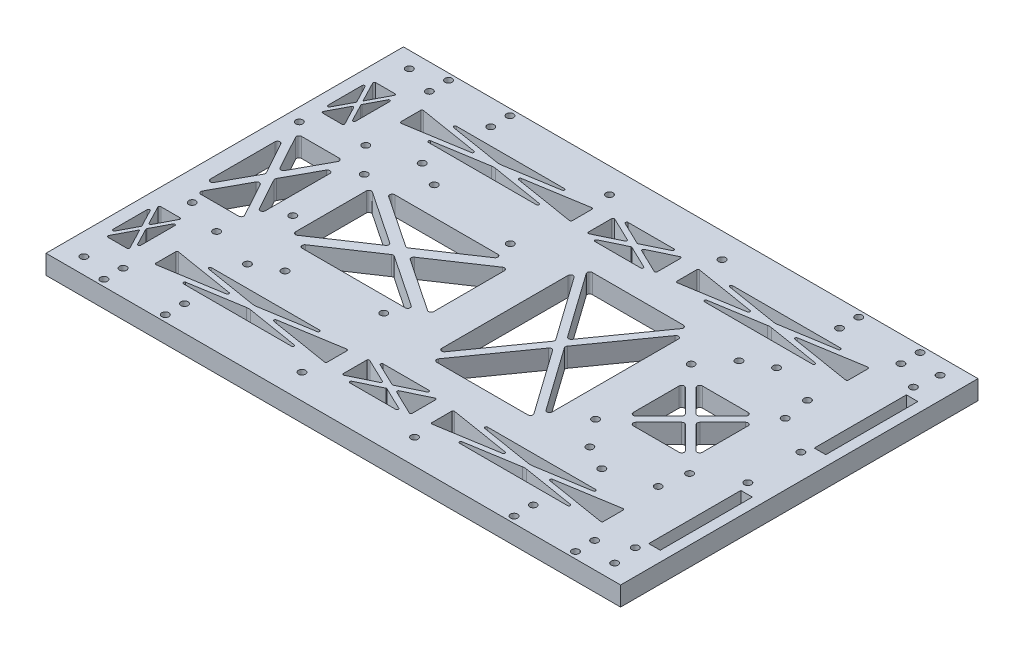
from build123d import *

# Parameters (mm, degrees)
SKETCH6_W                               = 224.59
SKETCH6_H                               = 139.7
CHASSISBASE_DEPTH                       = 7.5
ARDUINOMEGAMOUNTINGHOLESSKETCH_R        = 1.375
ARDUINOMEGAMOUNTINGHOLES_DEPTH          = 7.5
FRONTMOTORMOUNTINGHOLESSKETCH_R         = 1.375
FRONTMOTORMOUNTINGHOLES_DEPTH           = 7.5
L298MOTORDRIVERMOUNTINGHOLESSKETCH_R    = 1.375
L298MOTORDRIVERMOUNTINGHOLES_DEPTH      = 7.5
COUPLINGCOLLARMOUNTINGHOLESSKETCH_R     = 1.375
COUPLINGCOLLARMOUNTINGHOLES_DEPTH       = 7.5
SIDEDISTANCESENSORMOUNTINGHOLESSKETCH_R = 1.375
SIDEDISTANCESENSORMOUNTINGHOLES_DEPTH   = 7.5
TOPCHASSISMOUNTINGHOLESSKETCH_R         = 1.375
TOPCHASSISMOUNTINGHOLES_DEPTH           = 7.5
REARSENSORMOUNTINGHOLESSKETCH_R         = 1.375
REARSENSORMOUNTINGHOLES_DEPTH           = 7.5
SKETCH7_W                               = 4.5
SKETCH7_H                               = 36
WEIGHTREDUCTION_DEPTH                   = 8.5


with BuildPart() as part:
    # Sketch6 → chassisBase (new body)
    with BuildSketch(Plane(origin=(0, 0, 0), x_dir=(1, 0, 0), z_dir=(0, 1, 0))):
        with Locations((112.295, 26.65)):
            Rectangle(SKETCH6_W, SKETCH6_H)
    extrude(amount=CHASSISBASE_DEPTH)

    # arduinoMegaMountingHolesSketch → arduinoMegaMountingHoles (cut)
    with BuildSketch(Plane(origin=(0, 0, 0), x_dir=(1, 0, 0), z_dir=(0, 1, 0))):
        with Locations((5.05, 50.76)):
            Circle(ARDUINOMEGAMOUNTINGHOLESSKETCH_R)
        with Locations((87.52, 50.76)):
            Circle(ARDUINOMEGAMOUNTINGHOLESSKETCH_R)
        with Locations((86.29, 2.54)):
            Circle(ARDUINOMEGAMOUNTINGHOLESSKETCH_R)
        with Locations((11.41, 2.54)):
            Circle(ARDUINOMEGAMOUNTINGHOLESSKETCH_R)
        with Locations((35.5, 45.68)):
            Circle(ARDUINOMEGAMOUNTINGHOLESSKETCH_R)
        with Locations((35.5, 17.77)):
            Circle(ARDUINOMEGAMOUNTINGHOLESSKETCH_R)
    extrude(amount=ARDUINOMEGAMOUNTINGHOLES_DEPTH, mode=Mode.SUBTRACT)

    # frontMotorMountingHolesSketch → frontMotorMountingHoles (cut)
    with BuildSketch(Plane(origin=(0, 0, 0), x_dir=(1, 0, 0), z_dir=(0, 1, 0))):
        with Locations((25.985, 55.8)):
            Circle(FRONTMOTORMOUNTINGHOLESSKETCH_R)
        with Locations((43.035, 60.8)):
            Circle(FRONTMOTORMOUNTINGHOLESSKETCH_R)
        with Locations((52.735, 55.8)):
            Circle(FRONTMOTORMOUNTINGHOLESSKETCH_R)
        with Locations((25.985, -2.5)):
            Circle(FRONTMOTORMOUNTINGHOLESSKETCH_R)
        with Locations((43.035, -7.5)):
            Circle(FRONTMOTORMOUNTINGHOLESSKETCH_R)
        with Locations((52.735, -2.5)):
            Circle(FRONTMOTORMOUNTINGHOLESSKETCH_R)
    extrude(amount=FRONTMOTORMOUNTINGHOLES_DEPTH, mode=Mode.SUBTRACT)

    # L298motorDriverMountingHolesSketch → L298motorDriverMountingHoles (cut)
    with BuildSketch(Plane(origin=(0, 0, 0), x_dir=(1, 0, 0), z_dir=(0, 1, 0))):
        with Locations((163.60569727, 45.38594237)):
            Circle(L298MOTORDRIVERMOUNTINGHOLESSKETCH_R)
        with Locations((163.60569727, 8.0064415)):
            Circle(L298MOTORDRIVERMOUNTINGHOLESSKETCH_R)
        with Locations((200.347497622, 45.38594237)):
            Circle(L298MOTORDRIVERMOUNTINGHOLESSKETCH_R)
        with Locations((200.34749759, 8.0064415)):
            Circle(L298MOTORDRIVERMOUNTINGHOLESSKETCH_R)
        with Locations((171.855, 55.8)):
            Circle(L298MOTORDRIVERMOUNTINGHOLESSKETCH_R)
        with Locations((181.555, 60.8)):
            Circle(L298MOTORDRIVERMOUNTINGHOLESSKETCH_R)
        with Locations((198.605, 55.8)):
            Circle(L298MOTORDRIVERMOUNTINGHOLESSKETCH_R)
        with Locations((198.605, -2.5)):
            Circle(L298MOTORDRIVERMOUNTINGHOLESSKETCH_R)
        with Locations((181.555, -7.5)):
            Circle(L298MOTORDRIVERMOUNTINGHOLESSKETCH_R)
        with Locations((171.855, -2.5)):
            Circle(L298MOTORDRIVERMOUNTINGHOLESSKETCH_R)
    extrude(amount=L298MOTORDRIVERMOUNTINGHOLES_DEPTH, mode=Mode.SUBTRACT)

    # couplingCollarMountingHolesSketch → couplingCollarMountingHoles (cut)
    with BuildSketch(Plane(origin=(0, 0, 0), x_dir=(1, 0, 0), z_dir=(0, 1, 0))):
        with Locations((20.135, 86.5)):
            Circle(COUPLINGCOLLARMOUNTINGHOLESSKETCH_R)
        with Locations((20.135, 94)):
            Circle(COUPLINGCOLLARMOUNTINGHOLESSKETCH_R)
        with Locations((44.135, 86.5)):
            Circle(COUPLINGCOLLARMOUNTINGHOLESSKETCH_R)
        with Locations((44.135, 94)):
            Circle(COUPLINGCOLLARMOUNTINGHOLESSKETCH_R)
        with Locations((204.455, 86.5)):
            Circle(COUPLINGCOLLARMOUNTINGHOLESSKETCH_R)
        with Locations((180.455, 86.5)):
            Circle(COUPLINGCOLLARMOUNTINGHOLESSKETCH_R)
        with Locations((180.455, 94)):
            Circle(COUPLINGCOLLARMOUNTINGHOLESSKETCH_R)
        with Locations((204.455, 94)):
            Circle(COUPLINGCOLLARMOUNTINGHOLESSKETCH_R)
        with Locations((20.135, -33.2)):
            Circle(COUPLINGCOLLARMOUNTINGHOLESSKETCH_R)
        with Locations((44.135, -33.2)):
            Circle(COUPLINGCOLLARMOUNTINGHOLESSKETCH_R)
        with Locations((44.135, -40.7)):
            Circle(COUPLINGCOLLARMOUNTINGHOLESSKETCH_R)
        with Locations((20.135, -40.7)):
            Circle(COUPLINGCOLLARMOUNTINGHOLESSKETCH_R)
        with Locations((180.455, -33.2)):
            Circle(COUPLINGCOLLARMOUNTINGHOLESSKETCH_R)
        with Locations((204.455, -33.2)):
            Circle(COUPLINGCOLLARMOUNTINGHOLESSKETCH_R)
        with Locations((204.455, -40.7)):
            Circle(COUPLINGCOLLARMOUNTINGHOLESSKETCH_R)
        with Locations((180.455, -40.7)):
            Circle(COUPLINGCOLLARMOUNTINGHOLESSKETCH_R)
    extrude(amount=COUPLINGCOLLARMOUNTINGHOLES_DEPTH, mode=Mode.SUBTRACT)

    # sideDistanceSensorMountingHolesSketch → sideDistanceSensorMountingHoles (cut)
    with BuildSketch(Plane(origin=(0, 0, 0), x_dir=(1, 0, 0), z_dir=(0, 1, 0))):
        with Locations((90.295, -33.45)):
            Circle(SIDEDISTANCESENSORMOUNTINGHOLESSKETCH_R)
        with Locations((134.295, -33.45)):
            Circle(SIDEDISTANCESENSORMOUNTINGHOLESSKETCH_R)
        with Locations((90.295, 86.75)):
            Circle(SIDEDISTANCESENSORMOUNTINGHOLESSKETCH_R)
        with Locations((134.295, 86.75)):
            Circle(SIDEDISTANCESENSORMOUNTINGHOLESSKETCH_R)
    extrude(amount=SIDEDISTANCESENSORMOUNTINGHOLES_DEPTH, mode=Mode.SUBTRACT)

    # topChassisMountingHolesSketch → topChassisMountingHoles (cut)
    with BuildSketch(Plane(origin=(0, 0, 0), x_dir=(1, 0, 0), z_dir=(0, 1, 0))):
        with Locations((8.5675, 90.25)):
            Circle(TOPCHASSISMOUNTINGHOLESSKETCH_R)
        with Locations((8.5675, -36.95)):
            Circle(TOPCHASSISMOUNTINGHOLESSKETCH_R)
        with Locations((216.0225, 90.25)):
            Circle(TOPCHASSISMOUNTINGHOLESSKETCH_R)
        with Locations((216.0225, -36.95)):
            Circle(TOPCHASSISMOUNTINGHOLESSKETCH_R)
    extrude(amount=TOPCHASSISMOUNTINGHOLES_DEPTH, mode=Mode.SUBTRACT)

    # rearSensorMountingHolesSketch → rearSensorMountingHoles (cut)
    with BuildSketch(Plane(origin=(0, 0, 0), x_dir=(1, 0, 0), z_dir=(0, 1, 0))):
        with Locations((214.84, 81)):
            Circle(REARSENSORMOUNTINGHOLESSKETCH_R)
        with Locations((214.84, 37)):
            Circle(REARSENSORMOUNTINGHOLESSKETCH_R)
        with Locations((214.84, -27.7)):
            Circle(REARSENSORMOUNTINGHOLESSKETCH_R)
        with Locations((214.84, 16.3)):
            Circle(REARSENSORMOUNTINGHOLESSKETCH_R)
    extrude(amount=REARSENSORMOUNTINGHOLES_DEPTH, mode=Mode.SUBTRACT)

    # Sketch7 → weightReduction (cut, through all)
    with BuildSketch(Plane(origin=(0, 7.5, 0), x_dir=(1, 0, 0), z_dir=(0, 1, 0))):
        with BuildLine():
            Line((170.362106781, 36.321572875), (179.326572875, 27.357106781))
            ThreePointArc((179.326572875, 27.357106781), (179.619466094, 26.65), (179.326572875, 25.942893219))
            Line((179.326572875, 25.942893219), (170.362106781, 16.978427125))
            ThreePointArc((170.362106781, 16.978427125), (169.272316568, 16.761654373), (168.655, 17.685533906))
            Line((168.655, 17.685533906), (168.655, 35.614466094))
            ThreePointArc((168.655, 35.614466094), (169.272316568, 36.538345627), (170.362106781, 36.321572875))
        make_face()
        with BuildLine():
            Line((172.483427125, 38.442893219), (181.447893219, 29.478427125))
            ThreePointArc((181.447893219, 29.478427125), (182.155, 29.185533906), (182.862106781, 29.478427125))
            Line((182.862106781, 29.478427125), (191.826572875, 38.442893219))
            ThreePointArc((191.826572875, 38.442893219), (192.043345627, 39.532683432), (191.119466094, 40.15))
            Line((191.119466094, 40.15), (173.190533906, 40.15))
            ThreePointArc((173.190533906, 40.15), (172.266654373, 39.532683432), (172.483427125, 38.442893219))
        make_face()
        with BuildLine():
            Line((173.190533906, 13.15), (191.119466094, 13.15))
            ThreePointArc((191.119466094, 13.15), (192.043345627, 13.767316568), (191.826572875, 14.857106781))
            Line((191.826572875, 14.857106781), (182.862106781, 23.821572875))
            ThreePointArc((182.862106781, 23.821572875), (182.155, 24.114466094), (181.447893219, 23.821572875))
            Line((181.447893219, 23.821572875), (172.483427125, 14.857106781))
            ThreePointArc((172.483427125, 14.857106781), (172.266654373, 13.767316568), (173.190533906, 13.15))
        make_face()
        with BuildLine():
            Line((195.655, 17.685533906), (195.655, 35.614466094))
            ThreePointArc((195.655, 35.614466094), (195.037683432, 36.538345627), (193.947893219, 36.321572875))
            Line((193.947893219, 36.321572875), (184.983427125, 27.357106781))
            ThreePointArc((184.983427125, 27.357106781), (184.690533906, 26.65), (184.983427125, 25.942893219))
            Line((184.983427125, 25.942893219), (193.947893219, 16.978427125))
            ThreePointArc((193.947893219, 16.978427125), (195.037683432, 16.761654373), (195.655, 17.685533906))
        make_face()
        with BuildLine():
            Line((113.294715761, -3.75), (148.880284239, -3.75))
            ThreePointArc((148.880284239, -3.75), (149.768717571, -3.209005681), (149.695876132, -2.17137243))
            Line((149.695876132, -2.17137243), (131.903091892, 22.908059163))
            ThreePointArc((131.903091892, 22.908059163), (131.0875, 23.329431593), (130.271908108, 22.908059163))
            Line((130.271908108, 22.908059163), (112.479123868, -2.17137243))
            ThreePointArc((112.479123868, -2.17137243), (112.406282429, -3.209005681), (113.294715761, -3.75))
        make_face()
        with BuildLine():
            Line((109.52, 1.980096633), (109.52, 51.319903367))
            ThreePointArc((109.52, 51.319903367), (110.216348796, 52.27268663), (111.335591892, 51.898530938))
            Line((111.335591892, 51.898530938), (128.837833368, 27.22862757))
            ThreePointArc((128.837833368, 27.22862757), (129.022241476, 26.65), (128.837833368, 26.07137243))
            Line((128.837833368, 26.07137243), (111.335591892, 1.401469062))
            ThreePointArc((111.335591892, 1.401469062), (110.216348796, 1.02731337), (109.52, 1.980096633))
        make_face()
        with BuildLine():
            Line((113.294715761, 57.05), (148.880284239, 57.05))
            ThreePointArc((148.880284239, 57.05), (149.768717571, 56.509005681), (149.695876132, 55.47137243))
            Line((149.695876132, 55.47137243), (131.903091892, 30.391940837))
            ThreePointArc((131.903091892, 30.391940837), (131.0875, 29.970568407), (130.271908108, 30.391940837))
            Line((130.271908108, 30.391940837), (112.479123868, 55.47137243))
            ThreePointArc((112.479123868, 55.47137243), (112.406282429, 56.509005681), (113.294715761, 57.05))
        make_face()
        with BuildLine():
            Line((152.655, 1.980096633), (152.655, 51.319903367))
            ThreePointArc((152.655, 51.319903367), (151.958651204, 52.27268663), (150.839408108, 51.898530938))
            Line((150.839408108, 51.898530938), (133.337166632, 27.22862757))
            ThreePointArc((133.337166632, 27.22862757), (133.152758524, 26.65), (133.337166632, 26.07137243))
            Line((133.337166632, 26.07137243), (150.839408108, 1.401469062))
            ThreePointArc((150.839408108, 1.401469062), (151.958651204, 1.02731337), (152.655, 1.980096633))
        make_face()
        with BuildLine():
            Line((103.334561275, 81), (121.255438725, 81))
            ThreePointArc((121.255438725, 81), (121.742926141, 80.611157634), (121.472190515, 80.049424078))
            Line((121.472190515, 80.049424078), (112.51175179, 75.738960427))
            ThreePointArc((112.51175179, 75.738960427), (112.295, 75.689536349), (112.07824821, 75.738960427))
            Line((112.07824821, 75.738960427), (103.117809485, 80.049424078))
            ThreePointArc((103.117809485, 80.049424078), (102.847073859, 80.611157634), (103.334561275, 81))
        make_face()
        with BuildLine():
            Line((125.755, 69.955063838), (125.755, 79.094936162))
            ThreePointArc((125.755, 79.094936162), (125.521105341, 79.518242136), (125.03824821, 79.545512084))
            Line((125.03824821, 79.545512084), (115.538427245, 74.975575922))
            ThreePointArc((115.538427245, 74.975575922), (115.255179035, 74.525), (115.538427245, 74.074424078))
            Line((115.538427245, 74.074424078), (125.03824821, 69.504487916))
            ThreePointArc((125.03824821, 69.504487916), (125.521105341, 69.531757864), (125.755, 69.955063838))
        make_face()
        with BuildLine():
            Line((37.11356333, -25.706546713), (57.528535299, -22.370069951))
            ThreePointArc((57.528535299, -22.370069951), (58.335, -22.304602825), (59.141464701, -22.370069951))
            Line((59.141464701, -22.370069951), (79.55643667, -25.706546713))
            ThreePointArc((79.55643667, -25.706546713), (79.974150834, -26.240455879), (79.4757902, -26.7))
            Line((79.4757902, -26.7), (37.1942098, -26.7))
            ThreePointArc((37.1942098, -26.7), (36.695849166, -26.240455879), (37.11356333, -25.706546713))
        make_face()
        with BuildLine():
            Line((6.672598406, 58.3), (14.162401594, 58.3))
            ThreePointArc((14.162401594, 58.3), (14.59014905, 58.541094392), (14.605386455, 59.031871544))
            Line((14.605386455, 59.031871544), (10.860484861, 66.186413584))
            ThreePointArc((10.860484861, 66.186413584), (10.4175, 66.454542039), (9.974515139, 66.186413584))
            Line((9.974515139, 66.186413584), (6.229613545, 59.031871544))
            ThreePointArc((6.229613545, 59.031871544), (6.24485095, 58.541094392), (6.672598406, 58.3))
        make_face()
        with BuildLine():
            Line((5, 61.950695617), (5, 75.349304383))
            ThreePointArc((5, 75.349304383), (5.380610784, 75.834841421), (5.942984861, 75.581175928))
            Line((5.942984861, 75.581175928), (9.449601431, 68.881871544))
            ThreePointArc((9.449601431, 68.881871544), (9.50661657, 68.65), (9.449601431, 68.418128456))
            Line((9.449601431, 68.418128456), (5.942984861, 61.718824072))
            ThreePointArc((5.942984861, 61.718824072), (5.380610784, 61.465158579), (5, 61.950695617))
        make_face()
        with BuildLine():
            Line((6.672598406, 79), (14.162401594, 79))
            ThreePointArc((14.162401594, 79), (14.59014905, 78.758905608), (14.605386455, 78.268128456))
            Line((14.605386455, 78.268128456), (10.4175, 70.267274776))
            Line((10.4175, 70.267274776), (6.229613545, 78.268128456))
            ThreePointArc((6.229613545, 78.268128456), (6.24485095, 78.758905608), (6.672598406, 79))
        make_face()
        with BuildLine():
            Line((15.835, 61.950695617), (15.835, 75.349304383))
            ThreePointArc((15.835, 75.349304383), (15.454389216, 75.834841421), (14.892015139, 75.581175928))
            Line((14.892015139, 75.581175928), (11.385398569, 68.881871544))
            ThreePointArc((11.385398569, 68.881871544), (11.32838343, 68.65), (11.385398569, 68.418128456))
            Line((11.385398569, 68.418128456), (14.892015139, 61.718824072))
            ThreePointArc((14.892015139, 61.718824072), (15.454389216, 61.465158579), (15.835, 61.950695617))
        make_face()
        with BuildLine():
            Line((24.835, -17.351617124), (24.835, -25.098382876))
            ThreePointArc((24.835, -25.098382876), (25.011212442, -25.479383686), (25.41564647, -25.591836163))
            Line((25.41564647, -25.591836163), (49.1157974, -21.718453287))
            ThreePointArc((49.1157974, -21.718453287), (49.53515093, -21.225), (49.1157974, -20.731546713))
            Line((49.1157974, -20.731546713), (25.41564647, -16.858163837))
            ThreePointArc((25.41564647, -16.858163837), (25.011212442, -16.970616314), (24.835, -17.351617124))
        make_face()
        with BuildLine():
            Line((91.835, -25.098382876), (91.835, -17.351617124))
            ThreePointArc((91.835, -17.351617124), (91.658787558, -16.970616314), (91.25435353, -16.858163837))
            Line((91.25435353, -16.858163837), (67.5542026, -20.731546713))
            ThreePointArc((67.5542026, -20.731546713), (67.13484907, -21.225), (67.5542026, -21.718453287))
            Line((67.5542026, -21.718453287), (91.25435353, -25.591836163))
            ThreePointArc((91.25435353, -25.591836163), (91.658787558, -25.479383686), (91.835, -25.098382876))
        make_face()
        with BuildLine():
            Line((79.4757902, -15.75), (37.1942098, -15.75))
            ThreePointArc((37.1942098, -15.75), (36.695849166, -16.209544121), (37.11356333, -16.743453287))
            Line((37.11356333, -16.743453287), (57.528535299, -20.079930049))
            ThreePointArc((57.528535299, -20.079930049), (58.335, -20.145397175), (59.141464701, -20.079930049))
            Line((59.141464701, -20.079930049), (79.55643667, -16.743453287))
            ThreePointArc((79.55643667, -16.743453287), (79.974150834, -16.209544121), (79.4757902, -15.75))
        make_face()
        with BuildLine():
            Line((10.396733566, 46.3), (25.103266434, 46.3))
            ThreePointArc((25.103266434, 46.3), (25.963483437, 45.809928139), (25.980564146, 44.820053415))
            Line((25.980564146, 44.820053415), (18.627297712, 31.378966398))
            ThreePointArc((18.627297712, 31.378966398), (17.75, 30.858912984), (16.872702288, 31.378966398))
            Line((16.872702288, 31.378966398), (9.519435854, 44.820053415))
            ThreePointArc((9.519435854, 44.820053415), (9.536516563, 45.809928139), (10.396733566, 46.3))
        make_face()
        with BuildLine():
            Line((28.5, 14.036819961), (28.5, 39.263180039))
            ThreePointArc((28.5, 39.263180039), (27.747691631, 40.232018961), (26.622702288, 39.743126625))
            Line((26.622702288, 39.743126625), (19.722362063, 27.129946585))
            ThreePointArc((19.722362063, 27.129946585), (19.599659775, 26.65), (19.722362063, 26.170053415))
            Line((19.722362063, 26.170053415), (26.622702288, 13.556873375))
            ThreePointArc((26.622702288, 13.556873375), (27.747691631, 13.067981039), (28.5, 14.036819961))
        make_face()
        with BuildLine():
            Line((10.396733566, 7), (25.103266434, 7))
            ThreePointArc((25.103266434, 7), (25.963483437, 7.490071861), (25.980564146, 8.479946585))
            Line((25.980564146, 8.479946585), (18.627297712, 21.921033602))
            ThreePointArc((18.627297712, 21.921033602), (17.75, 22.441087016), (16.872702288, 21.921033602))
            Line((16.872702288, 21.921033602), (9.519435854, 8.479946585))
            ThreePointArc((9.519435854, 8.479946585), (9.536516563, 7.490071861), (10.396733566, 7))
        make_face()
        with BuildLine():
            Line((7, 14.036819961), (7, 39.263180039))
            ThreePointArc((7, 39.263180039), (7.752308369, 40.232018961), (8.877297712, 39.743126625))
            Line((8.877297712, 39.743126625), (15.777637937, 27.129946585))
            ThreePointArc((15.777637937, 27.129946585), (15.900340225, 26.65), (15.777637937, 26.170053415))
            Line((15.777637937, 26.170053415), (8.877297712, 13.556873375))
            ThreePointArc((8.877297712, 13.556873375), (7.752308369, 13.067981039), (7, 14.036819961))
        make_face()
        with BuildLine():
            Line((48.37842286, 44.76), (88.64157714, 44.76))
            ThreePointArc((88.64157714, 44.76), (89.598285248, 44.051049131), (89.198475267, 42.929419193))
            Line((89.198475267, 42.929419193), (69.066898127, 29.431349515))
            ThreePointArc((69.066898127, 29.431349515), (68.51, 29.261930322), (67.953101873, 29.431349515))
            Line((67.953101873, 29.431349515), (47.821524733, 42.929419193))
            ThreePointArc((47.821524733, 42.929419193), (47.421714752, 44.051049131), (48.37842286, 44.76))
        make_face()
        with BuildLine():
            Line((95.52, 12.822422732), (95.52, 40.477577268))
            ThreePointArc((95.52, 40.477577268), (94.990691976, 41.359874873), (93.963101873, 41.308158075))
            Line((93.963101873, 41.308158075), (73.34008354, 27.480580807))
            ThreePointArc((73.34008354, 27.480580807), (72.896981667, 26.65), (73.34008354, 25.819419193))
            Line((73.34008354, 25.819419193), (93.963101873, 11.991841925))
            ThreePointArc((93.963101873, 11.991841925), (94.990691976, 11.940125127), (95.52, 12.822422732))
        make_face()
        with BuildLine():
            Line((48.37842286, 8.54), (88.64157714, 8.54))
            ThreePointArc((88.64157714, 8.54), (89.598285248, 9.248950869), (89.198475267, 10.370580807))
            Line((89.198475267, 10.370580807), (69.066898127, 23.868650485))
            ThreePointArc((69.066898127, 23.868650485), (68.51, 24.038069678), (67.953101873, 23.868650485))
            Line((67.953101873, 23.868650485), (47.821524733, 10.370580807))
            ThreePointArc((47.821524733, 10.370580807), (47.421714752, 9.248950869), (48.37842286, 8.54))
        make_face()
        with BuildLine():
            Line((41.5, 12.822422732), (41.5, 40.477577268))
            ThreePointArc((41.5, 40.477577268), (42.029308024, 41.359874873), (43.056898127, 41.308158075))
            Line((43.056898127, 41.308158075), (63.67991646, 27.480580807))
            ThreePointArc((63.67991646, 27.480580807), (64.123018333, 26.65), (63.67991646, 25.819419193))
            Line((63.67991646, 25.819419193), (43.056898127, 11.991841925))
            ThreePointArc((43.056898127, 11.991841925), (42.029308024, 11.940125127), (41.5, 12.822422732))
        make_face()
        with BuildLine():
            Line((103.334561275, 68.05), (121.255438725, 68.05))
            ThreePointArc((121.255438725, 68.05), (121.742926141, 68.438842366), (121.472190515, 69.000575922))
            Line((121.472190515, 69.000575922), (112.51175179, 73.311039573))
            ThreePointArc((112.51175179, 73.311039573), (112.295, 73.360463651), (112.07824821, 73.311039573))
            Line((112.07824821, 73.311039573), (103.117809485, 69.000575922))
            ThreePointArc((103.117809485, 69.000575922), (102.847073859, 68.438842366), (103.334561275, 68.05))
        make_face()
        with BuildLine():
            Line((98.835, 69.955063838), (98.835, 79.094936162))
            ThreePointArc((98.835, 79.094936162), (99.068894659, 79.518242136), (99.55175179, 79.545512084))
            Line((99.55175179, 79.545512084), (109.051572755, 74.975575922))
            ThreePointArc((109.051572755, 74.975575922), (109.334820965, 74.525), (109.051572755, 74.074424078))
            Line((109.051572755, 74.074424078), (99.55175179, 69.504487916))
            ThreePointArc((99.55175179, 69.504487916), (99.068894659, 69.531757864), (98.835, 69.955063838))
        make_face()
        with BuildLine():
            Line((25.41564647, 70.158163837), (49.1157974, 74.031546713))
            ThreePointArc((49.1157974, 74.031546713), (49.53515093, 74.525), (49.1157974, 75.018453287))
            Line((49.1157974, 75.018453287), (25.41564647, 78.891836163))
            ThreePointArc((25.41564647, 78.891836163), (25.011212442, 78.779383686), (24.835, 78.398382876))
            Line((24.835, 78.398382876), (24.835, 70.651617124))
            ThreePointArc((24.835, 70.651617124), (25.011212442, 70.270616314), (25.41564647, 70.158163837))
        make_face()
        with BuildLine():
            Line((37.11356333, 79.006546713), (57.528535299, 75.670069951))
            ThreePointArc((57.528535299, 75.670069951), (58.335, 75.604602825), (59.141464701, 75.670069951))
            Line((59.141464701, 75.670069951), (79.55643667, 79.006546713))
            ThreePointArc((79.55643667, 79.006546713), (79.974150834, 79.540455879), (79.4757902, 80))
            Line((79.4757902, 80), (37.1942098, 80))
            ThreePointArc((37.1942098, 80), (36.695849166, 79.540455879), (37.11356333, 79.006546713))
        make_face()
        with BuildLine():
            Line((67.5542026, 75.018453287), (91.25435353, 78.891836163))
            ThreePointArc((91.25435353, 78.891836163), (91.658787558, 78.779383686), (91.835, 78.398382876))
            Line((91.835, 78.398382876), (91.835, 70.651617124))
            ThreePointArc((91.835, 70.651617124), (91.658787558, 70.270616314), (91.25435353, 70.158163837))
            Line((91.25435353, 70.158163837), (67.5542026, 74.031546713))
            ThreePointArc((67.5542026, 74.031546713), (67.13484907, 74.525), (67.5542026, 75.018453287))
        make_face()
        with BuildLine():
            Line((59.141464701, 73.379930049), (79.55643667, 70.043453287))
            ThreePointArc((79.55643667, 70.043453287), (79.974150834, 69.509544121), (79.4757902, 69.05))
            Line((79.4757902, 69.05), (37.1942098, 69.05))
            ThreePointArc((37.1942098, 69.05), (36.695849166, 69.509544121), (37.11356333, 70.043453287))
            Line((37.11356333, 70.043453287), (57.528535299, 73.379930049))
            ThreePointArc((57.528535299, 73.379930049), (58.335, 73.445397175), (59.141464701, 73.379930049))
        make_face()
        with BuildLine():
            Line((157.0357974, -21.718453287), (133.33564647, -25.591836163))
            ThreePointArc((133.33564647, -25.591836163), (132.931212442, -25.479383686), (132.755, -25.098382876))
            Line((132.755, -25.098382876), (132.755, -17.351617124))
            ThreePointArc((132.755, -17.351617124), (132.931212442, -16.970616314), (133.33564647, -16.858163837))
            Line((133.33564647, -16.858163837), (157.0357974, -20.731546713))
            ThreePointArc((157.0357974, -20.731546713), (157.45515093, -21.225), (157.0357974, -21.718453287))
        make_face()
        with BuildLine():
            Line((187.47643667, -25.706546713), (167.061464701, -22.370069951))
            ThreePointArc((167.061464701, -22.370069951), (166.255, -22.304602825), (165.448535299, -22.370069951))
            Line((165.448535299, -22.370069951), (145.03356333, -25.706546713))
            ThreePointArc((145.03356333, -25.706546713), (144.615849166, -26.240455879), (145.1142098, -26.7))
            Line((145.1142098, -26.7), (187.3957902, -26.7))
            ThreePointArc((187.3957902, -26.7), (187.894150834, -26.240455879), (187.47643667, -25.706546713))
        make_face()
        with BuildLine():
            Line((199.17435353, -16.858163837), (175.4742026, -20.731546713))
            ThreePointArc((175.4742026, -20.731546713), (175.05484907, -21.225), (175.4742026, -21.718453287))
            Line((175.4742026, -21.718453287), (199.17435353, -25.591836163))
            ThreePointArc((199.17435353, -25.591836163), (199.578787558, -25.479383686), (199.755, -25.098382876))
            Line((199.755, -25.098382876), (199.755, -17.351617124))
            ThreePointArc((199.755, -17.351617124), (199.578787558, -16.970616314), (199.17435353, -16.858163837))
        make_face()
        with BuildLine():
            Line((165.448535299, -20.079930049), (145.03356333, -16.743453287))
            ThreePointArc((145.03356333, -16.743453287), (144.615849166, -16.209544121), (145.1142098, -15.75))
            Line((145.1142098, -15.75), (187.3957902, -15.75))
            ThreePointArc((187.3957902, -15.75), (187.894150834, -16.209544121), (187.47643667, -16.743453287))
            Line((187.47643667, -16.743453287), (167.061464701, -20.079930049))
            ThreePointArc((167.061464701, -20.079930049), (166.255, -20.145397175), (165.448535299, -20.079930049))
        make_face()
        with BuildLine():
            Line((187.47643667, 70.043453287), (167.061464701, 73.379930049))
            ThreePointArc((167.061464701, 73.379930049), (166.255, 73.445397175), (165.448535299, 73.379930049))
            Line((165.448535299, 73.379930049), (145.03356333, 70.043453287))
            ThreePointArc((145.03356333, 70.043453287), (144.615849166, 69.509544121), (145.1142098, 69.05))
            Line((145.1142098, 69.05), (187.3957902, 69.05))
            ThreePointArc((187.3957902, 69.05), (187.894150834, 69.509544121), (187.47643667, 70.043453287))
        make_face()
        with BuildLine():
            Line((157.0357974, 74.031546713), (133.33564647, 70.158163837))
            ThreePointArc((133.33564647, 70.158163837), (132.931212442, 70.270616314), (132.755, 70.651617124))
            Line((132.755, 70.651617124), (132.755, 78.398382876))
            ThreePointArc((132.755, 78.398382876), (132.931212442, 78.779383686), (133.33564647, 78.891836163))
            Line((133.33564647, 78.891836163), (157.0357974, 75.018453287))
            ThreePointArc((157.0357974, 75.018453287), (157.45515093, 74.525), (157.0357974, 74.031546713))
        make_face()
        with BuildLine():
            Line((187.3957902, 80), (145.1142098, 80))
            ThreePointArc((145.1142098, 80), (144.615849166, 79.540455879), (145.03356333, 79.006546713))
            Line((145.03356333, 79.006546713), (165.448535299, 75.670069951))
            ThreePointArc((165.448535299, 75.670069951), (166.255, 75.604602825), (167.061464701, 75.670069951))
            Line((167.061464701, 75.670069951), (187.47643667, 79.006546713))
            ThreePointArc((187.47643667, 79.006546713), (187.894150834, 79.540455879), (187.3957902, 80))
        make_face()
        with BuildLine():
            Line((199.755, 70.651617124), (199.755, 78.398382876))
            ThreePointArc((199.755, 78.398382876), (199.578787558, 78.779383686), (199.17435353, 78.891836163))
            Line((199.17435353, 78.891836163), (175.4742026, 75.018453287))
            ThreePointArc((175.4742026, 75.018453287), (175.05484907, 74.525), (175.4742026, 74.031546713))
            Line((175.4742026, 74.031546713), (199.17435353, 70.158163837))
            ThreePointArc((199.17435353, 70.158163837), (199.578787558, 70.270616314), (199.755, 70.651617124))
        make_face()
        with BuildLine():
            Line((5, -8.650695617), (5, -22.049304383))
            ThreePointArc((5, -22.049304383), (5.380610784, -22.534841421), (5.942984861, -22.281175928))
            Line((5.942984861, -22.281175928), (9.449601431, -15.581871544))
            ThreePointArc((9.449601431, -15.581871544), (9.50661657, -15.35), (9.449601431, -15.118128456))
            Line((9.449601431, -15.118128456), (5.942984861, -8.418824072))
            ThreePointArc((5.942984861, -8.418824072), (5.380610784, -8.165158579), (5, -8.650695617))
        make_face()
        with BuildLine():
            Line((6.229613545, -5.731871544), (9.974515139, -12.886413584))
            ThreePointArc((9.974515139, -12.886413584), (10.4175, -13.154542039), (10.860484861, -12.886413584))
            Line((10.860484861, -12.886413584), (14.605386455, -5.731871544))
            ThreePointArc((14.605386455, -5.731871544), (14.59014905, -5.241094392), (14.162401594, -5))
            Line((14.162401594, -5), (6.672598406, -5))
            ThreePointArc((6.672598406, -5), (6.24485095, -5.241094392), (6.229613545, -5.731871544))
        make_face()
        with BuildLine():
            Line((11.385398569, -15.581871544), (14.892015139, -22.281175928))
            ThreePointArc((14.892015139, -22.281175928), (15.454389216, -22.534841421), (15.835, -22.049304383))
            Line((15.835, -22.049304383), (15.835, -8.650695617))
            ThreePointArc((15.835, -8.650695617), (15.454389216, -8.165158579), (14.892015139, -8.418824072))
            Line((14.892015139, -8.418824072), (11.385398569, -15.118128456))
            ThreePointArc((11.385398569, -15.118128456), (11.32838343, -15.35), (11.385398569, -15.581871544))
        make_face()
        with BuildLine():
            Line((6.229613545, -24.968128456), (10.4175, -16.967274776))
            Line((10.4175, -16.967274776), (14.605386455, -24.968128456))
            ThreePointArc((14.605386455, -24.968128456), (14.59014905, -25.458905608), (14.162401594, -25.7))
            Line((14.162401594, -25.7), (6.672598406, -25.7))
            ThreePointArc((6.672598406, -25.7), (6.24485095, -25.458905608), (6.229613545, -24.968128456))
        make_face()
        with BuildLine():
            Line((115.538427245, -20.774424078), (125.03824821, -16.204487916))
            ThreePointArc((125.03824821, -16.204487916), (125.521105341, -16.231757864), (125.755, -16.655063838))
            Line((125.755, -16.655063838), (125.755, -25.794936162))
            ThreePointArc((125.755, -25.794936162), (125.521105341, -26.218242136), (125.03824821, -26.245512084))
            Line((125.03824821, -26.245512084), (115.538427245, -21.675575922))
            ThreePointArc((115.538427245, -21.675575922), (115.255179035, -21.225), (115.538427245, -20.774424078))
        make_face()
        with BuildLine():
            Line((103.117809485, -15.700575922), (112.07824821, -20.011039573))
            ThreePointArc((112.07824821, -20.011039573), (112.295, -20.060463651), (112.51175179, -20.011039573))
            Line((112.51175179, -20.011039573), (121.472190515, -15.700575922))
            ThreePointArc((121.472190515, -15.700575922), (121.742926141, -15.138842366), (121.255438725, -14.75))
            Line((121.255438725, -14.75), (103.334561275, -14.75))
            ThreePointArc((103.334561275, -14.75), (102.847073859, -15.138842366), (103.117809485, -15.700575922))
        make_face()
        with BuildLine():
            Line((99.55175179, -16.204487916), (109.051572755, -20.774424078))
            ThreePointArc((109.051572755, -20.774424078), (109.334820965, -21.225), (109.051572755, -21.675575922))
            Line((109.051572755, -21.675575922), (99.55175179, -26.245512084))
            ThreePointArc((99.55175179, -26.245512084), (99.068894659, -26.218242136), (98.835, -25.794936162))
            Line((98.835, -25.794936162), (98.835, -16.655063838))
            ThreePointArc((98.835, -16.655063838), (99.068894659, -16.231757864), (99.55175179, -16.204487916))
        make_face()
        with BuildLine():
            Line((103.117809485, -26.749424078), (112.07824821, -22.438960427))
            ThreePointArc((112.07824821, -22.438960427), (112.295, -22.389536349), (112.51175179, -22.438960427))
            Line((112.51175179, -22.438960427), (121.472190515, -26.749424078))
            ThreePointArc((121.472190515, -26.749424078), (121.742926141, -27.311157634), (121.255438725, -27.7))
            Line((121.255438725, -27.7), (103.334561275, -27.7))
            ThreePointArc((103.334561275, -27.7), (102.847073859, -27.311157634), (103.117809485, -26.749424078))
        make_face()
        with Locations((218.34, 59)):
            Rectangle(SKETCH7_W, SKETCH7_H)
        with Locations((218.34, -5.7)):
            Rectangle(SKETCH7_W, SKETCH7_H)
    extrude(amount=-WEIGHTREDUCTION_DEPTH, mode=Mode.SUBTRACT)


solid = part.part
